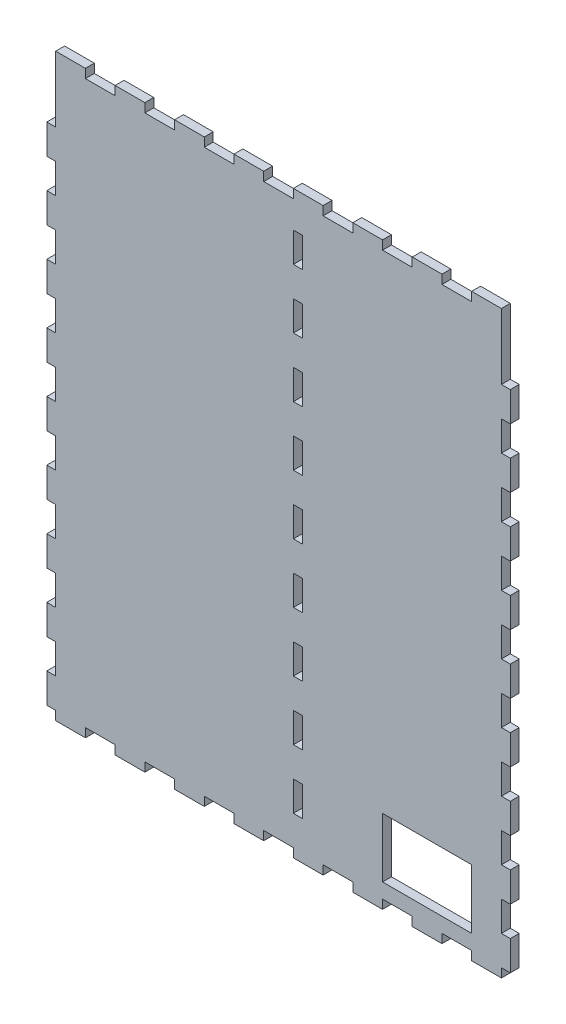
from build123d import *

# Parameters (mm, degrees)
ESQUISSE1_W                = 150
ESQUISSE1_H                = 189.15
BOSS_EXTRU_1_DEPTH         = 3
ESQUISSE2_W                = 10
ESQUISSE2_H                = 3
BOSS_EXTRU_2_DEPTH         = 3
R_P_TITION_LIN_AIRE1_COUNT = 8
R_P_TITION_LIN_AIRE1_PITCH = 20
ESQUISSE3_W                = 10
ESQUISSE3_H                = 3
BOSS_EXTRU_3_DEPTH         = 3
R_P_TITION_LIN_AIRE2_COUNT = 8
R_P_TITION_LIN_AIRE2_PITCH = 20
ESQUISSE4_W                = 3
ESQUISSE4_H                = 10
BOSS_EXTRU_4_DEPTH         = 3
R_P_TITION_LIN_AIRE3_COUNT = 9
R_P_TITION_LIN_AIRE3_PITCH = 20
ESQUISSE5_W                = 3
ESQUISSE5_H                = 10
BOSS_EXTRU_5_DEPTH         = 3
R_P_TITION_LIN_AIRE4_COUNT = 9
R_P_TITION_LIN_AIRE4_PITCH = 20
ESQUISSE6_W                = 30
ESQUISSE6_H                = 20
ENL_V_MAT_EXTRU_1_DEPTH    = 4
ESQUISSE7_W                = 3
ESQUISSE7_H                = 10
ENL_V_MAT_EXTRU_2_DEPTH    = 4
R_P_TITION_LIN_AIRE5_COUNT = 9
R_P_TITION_LIN_AIRE5_PITCH = 20


with BuildPart() as part:
    # Esquisse1 → Boss.-Extru.1 (new body)
    with BuildSketch(Plane.XY):
        with Locations((75, -94.575)):
            Rectangle(ESQUISSE1_W, ESQUISSE1_H)
    extrude(amount=BOSS_EXTRU_1_DEPTH)

    # Esquisse2 → Boss.-Extru.2 (add)
    with BuildSketch(Plane(origin=(0, 0, 0), x_dir=(1, 0, 0), z_dir=(0, 1, 0))):
        with Locations((5, -1.5)):
            Rectangle(ESQUISSE2_W, ESQUISSE2_H)
    boss_extru_2 = extrude(amount=BOSS_EXTRU_2_DEPTH)

    # Répétition linéaire1: Boss.-Extru.2 ×8
    with Locations(*[(i * R_P_TITION_LIN_AIRE1_PITCH, 0, 0) for i in range(1, R_P_TITION_LIN_AIRE1_COUNT)]):
        add(boss_extru_2)

    # Esquisse3 → Boss.-Extru.3 (add)
    with BuildSketch(Plane.XZ.offset(189.15)):
        with Locations((5, 1.5)):
            Rectangle(ESQUISSE3_W, ESQUISSE3_H)
    boss_extru_3 = extrude(amount=BOSS_EXTRU_3_DEPTH)

    # Répétition linéaire2: Boss.-Extru.3 ×8
    with Locations(*[(i * R_P_TITION_LIN_AIRE2_PITCH, 0, 0) for i in range(1, R_P_TITION_LIN_AIRE2_COUNT)]):
        add(boss_extru_3)

    # Esquisse4 → Boss.-Extru.4 (add)
    with BuildSketch(Plane.ZY):
        with Locations((1.5, -184.15)):
            Rectangle(ESQUISSE4_W, ESQUISSE4_H)
    boss_extru_4 = extrude(amount=BOSS_EXTRU_4_DEPTH)

    # Répétition linéaire3: Boss.-Extru.4 ×9
    with Locations(*[(0, i * R_P_TITION_LIN_AIRE3_PITCH, 0) for i in range(1, R_P_TITION_LIN_AIRE3_COUNT)]):
        add(boss_extru_4)

    # Esquisse5 → Boss.-Extru.5 (add)
    with BuildSketch(Plane(origin=(150, 0, 0), x_dir=(0, 0, -1), z_dir=(1, 0, 0))):
        with Locations((-1.5, -184.15)):
            Rectangle(ESQUISSE5_W, ESQUISSE5_H)
    boss_extru_5 = extrude(amount=BOSS_EXTRU_5_DEPTH)

    # Répétition linéaire4: Boss.-Extru.5 ×9
    with Locations(*[(0, i * R_P_TITION_LIN_AIRE4_PITCH, 0) for i in range(1, R_P_TITION_LIN_AIRE4_COUNT)]):
        add(boss_extru_5)

    # Esquisse6 → Enlèv. mat.-Extru.1 (cut, through all)
    with BuildSketch(Plane(origin=(0, 0, 0), x_dir=(-1, 0, 0), z_dir=(0, 0, -1))):
        with Locations((-125, -174.15)):
            Rectangle(ESQUISSE6_W, ESQUISSE6_H)
    extrude(amount=-ENL_V_MAT_EXTRU_1_DEPTH, mode=Mode.SUBTRACT)

    # Esquisse7 → Enlèv. mat.-Extru.2 (cut, through all)
    with BuildSketch(Plane(origin=(0, 0, 0), x_dir=(-1, 0, 0), z_dir=(0, 0, -1))):
        with Locations((-81.5, -14.15)):
            Rectangle(ESQUISSE7_W, ESQUISSE7_H)
    enl_v_mat_extru_2 = extrude(amount=-ENL_V_MAT_EXTRU_2_DEPTH, mode=Mode.SUBTRACT)

    # Répétition linéaire5: Enlèv. mat.-Extru.2 ×9
    with Locations(*[(0, -i * R_P_TITION_LIN_AIRE5_PITCH, 0) for i in range(1, R_P_TITION_LIN_AIRE5_COUNT)]):
        add(enl_v_mat_extru_2, mode=Mode.SUBTRACT)


solid = part.part
